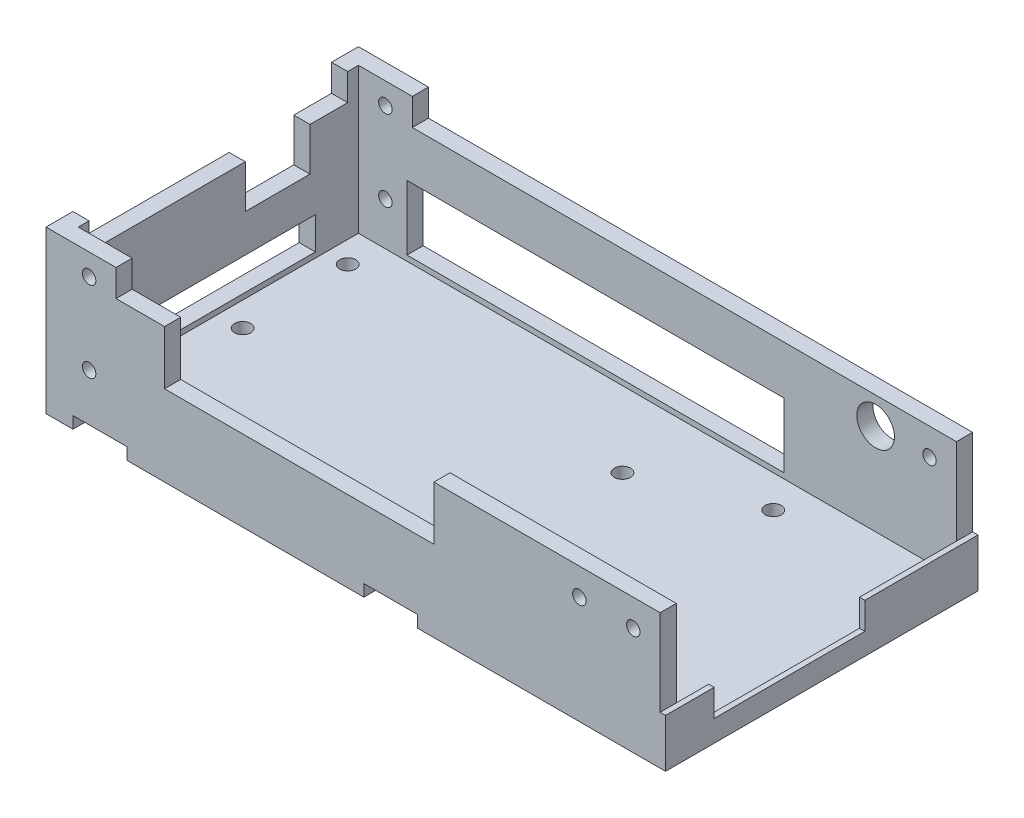
from build123d import *

# Parameters (mm, degrees)
SKETCH2_W           = 114
SKETCH2_H           = 58
BOSS_EXTRUDE1_DEPTH = 3
SKETCH3_R           = 1.5
CUT_EXTRUDE5_DEPTH  = 4
SKETCH5_R           = 3.025
CUT_EXTRUDE7_DEPTH  = 2.5
SKETCH7_W           = 3
SKETCH7_H           = 52
BOSS_EXTRUDE2_DEPTH = 22
CUT_EXTRUDE8_REACH  = 5
SKETCH8_R           = 1.5
CUT_EXTRUDE9_REACH  = 60
SKETCH9_W           = 50
SKETCH9_H           = 10
CUT_EXTRUDE10_REACH = 116
SKETCH10_W          = 32
SKETCH10_H          = 6
SKETCH10_W_2        = 12
SKETCH10_H_2        = 8
CUT_EXTRUDE11_REACH = 60
SKETCH11_W          = 70
SKETCH11_H          = 12
SKETCH12_R          = 1.25
CUT_EXTRUDE12_DEPTH = 59
SKETCH13_W          = 13
SKETCH13_H          = 5
BOSS_EXTRUDE4_DEPTH = 3
SKETCH14_W          = 13
SKETCH14_H          = 5
BOSS_EXTRUDE5_DEPTH = 3
SKETCH15_R          = 1.25
CUT_EXTRUDE13_DEPTH = 59
SKETCH16_W          = 2
SKETCH16_H          = 5
BOSS_EXTRUDE6_DEPTH = 3
CUT_EXTRUDE14_REACH = 5
SKETCH17_R          = 3.5
SKETCH19_W          = 1
SKETCH19_H          = 58
BOSS_EXTRUDE7_DEPTH = 9
CUT_EXTRUDE15_REACH = 117
SKETCH20_W          = 28
SKETCH20_H          = 5
SKETCH21_W          = 10
SKETCH21_H          = 2.5
CUT_EXTRUDE16_DEPTH = 2.2


with BuildPart() as part:
    # Sketch2 → Boss-Extrude1 (new body)
    with BuildSketch(Plane(origin=(0, 0, 0), x_dir=(1, 0, 0), z_dir=(0, 1, 0))):
        with Locations((-19.486211897, 1.601935214)):
            Rectangle(SKETCH2_W, SKETCH2_H)
    extrude(amount=BOSS_EXTRUDE1_DEPTH)

    # Sketch3 → Cut-Extrude5 (cut, through all)
    with BuildSketch(Plane(origin=(0, 3, 0), x_dir=(1, 0, 0), z_dir=(0, 1, 0))):
        with Locations((-10.486211897, 13.601935214)):
            Circle(SKETCH3_R)
        with Locations((-10.486211897, -10.398064786)):
            Circle(SKETCH3_R)
        with Locations((-68.986211897, 1.601935214)):
            Circle(SKETCH3_R)
    extrude(amount=-CUT_EXTRUDE5_DEPTH, mode=Mode.SUBTRACT)

    # Sketch5 → Cut-Extrude7 (cut)
    with BuildSketch(Plane(origin=(0, 0, 0), x_dir=(-1, 0, 0), z_dir=(0, -1, 0))):
        with Locations((23.486211897, 16.851935214)):
            Circle(SKETCH5_R)
        with Locations((23.486211897, -13.648064786)):
            Circle(SKETCH5_R)
        with Locations((53.986211897, -13.648064786)):
            Circle(SKETCH5_R)
        with Locations((53.986211897, 16.851935214)):
            Circle(SKETCH5_R)
    extrude(amount=-CUT_EXTRUDE7_DEPTH, mode=Mode.SUBTRACT)

    # Sketch7 → Boss-Extrude2 (add)
    with BuildSketch(Plane(origin=(0, 3, 0), x_dir=(1, 0, 0), z_dir=(0, 1, 0))):
        Polygon((37.513788103, 30.601935214), (-76.486211897, 30.601935214), (-76.486211897, 27.601935214), (-73.486211897, 27.601935214), (37.513788103, 27.601935214), align=None)
        with Locations((-74.986211897, 1.601935214)):
            Rectangle(SKETCH7_W, SKETCH7_H)
        Polygon((-73.486211897, -24.398064786), (-76.486211897, -24.398064786), (-76.486211897, -27.398064786), (37.513788103, -27.398064786), (37.513788103, -24.398064786), align=None)
    extrude(amount=BOSS_EXTRUDE2_DEPTH)

    # Sketch8 → Cut-Extrude8 (cut, up to next)
    with BuildSketch(Plane(origin=(0, 3, 0), x_dir=(1, 0, 0), z_dir=(0, 1, 0)), mode=Mode.PRIVATE) as cut_extrude8_sk1:
        with Locations((-69.486211897, 21.601935214)):
            Circle(SKETCH8_R)
    cut_extrude8_tool1 = extrude(cut_extrude8_sk1.sketch, amount=-CUT_EXTRUDE8_REACH, mode=Mode.PRIVATE) & part.part
    add(cut_extrude8_tool1.solids().sort_by_distance((-69.486212, 3, -21.601935))[0], mode=Mode.SUBTRACT)
    # Sketch8 → Cut-Extrude8 (cut, up to next)
    with BuildSketch(Plane(origin=(0, 3, 0), x_dir=(1, 0, 0), z_dir=(0, 1, 0)), mode=Mode.PRIVATE) as cut_extrude8_sk2:
        with Locations((-69.486211897, -20.398064786)):
            Circle(SKETCH8_R)
    cut_extrude8_tool2 = extrude(cut_extrude8_sk2.sketch, amount=-CUT_EXTRUDE8_REACH, mode=Mode.PRIVATE) & part.part
    add(cut_extrude8_tool2.solids().sort_by_distance((-69.486212, 3, 20.398065))[0], mode=Mode.SUBTRACT)
    # Sketch8 → Cut-Extrude8 (cut, up to next)
    with BuildSketch(Plane(origin=(0, 3, 0), x_dir=(1, 0, 0), z_dir=(0, 1, 0)), mode=Mode.PRIVATE) as cut_extrude8_sk3:
        with Locations((9.513788103, 21.601935214)):
            Circle(SKETCH8_R)
    cut_extrude8_tool3 = extrude(cut_extrude8_sk3.sketch, amount=-CUT_EXTRUDE8_REACH, mode=Mode.PRIVATE) & part.part
    add(cut_extrude8_tool3.solids().sort_by_distance((9.513788, 3, -21.601935))[0], mode=Mode.SUBTRACT)
    # Sketch8 → Cut-Extrude8 (cut, up to next)
    with BuildSketch(Plane(origin=(0, 3, 0), x_dir=(1, 0, 0), z_dir=(0, 1, 0)), mode=Mode.PRIVATE) as cut_extrude8_sk4:
        with Locations((9.513788103, -20.398064786)):
            Circle(SKETCH8_R)
    cut_extrude8_tool4 = extrude(cut_extrude8_sk4.sketch, amount=-CUT_EXTRUDE8_REACH, mode=Mode.PRIVATE) & part.part
    add(cut_extrude8_tool4.solids().sort_by_distance((9.513788, 3, 20.398065))[0], mode=Mode.SUBTRACT)

    # Sketch9 → Cut-Extrude9 (cut, up to next)
    with BuildSketch(Plane.XY.offset(27.398064786), mode=Mode.PRIVATE) as cut_extrude9_sk1:
        with Locations((-29.486211897, 20)):
            Rectangle(SKETCH9_W, SKETCH9_H)
    cut_extrude9_tool1 = extrude(cut_extrude9_sk1.sketch, amount=-CUT_EXTRUDE9_REACH, mode=Mode.PRIVATE) & part.part
    add(cut_extrude9_tool1.solids().sort_by_distance((-29.486212, 20, 27.398065))[0], mode=Mode.SUBTRACT)

    # Sketch10 → Cut-Extrude10 (cut, up to next)
    with BuildSketch(Plane.ZY.offset(76.486211897), mode=Mode.PRIVATE) as cut_extrude10_sk1:
        with Locations((-3.601935214, 7)):
            Rectangle(SKETCH10_W, SKETCH10_H)
    cut_extrude10_tool1 = extrude(cut_extrude10_sk1.sketch, amount=-CUT_EXTRUDE10_REACH, mode=Mode.PRIVATE) & part.part
    add(cut_extrude10_tool1.solids().sort_by_distance((-76.486212, 7, -3.601935))[0], mode=Mode.SUBTRACT)
    # Sketch10 → Cut-Extrude10 (cut, up to next)
    with BuildSketch(Plane.ZY.offset(76.486211897), mode=Mode.PRIVATE) as cut_extrude10_sk2:
        with Locations((-12.601935214, 21)):
            Rectangle(SKETCH10_W_2, SKETCH10_H_2)
    cut_extrude10_tool2 = extrude(cut_extrude10_sk2.sketch, amount=-CUT_EXTRUDE10_REACH, mode=Mode.PRIVATE) & part.part
    add(cut_extrude10_tool2.solids().sort_by_distance((-76.486212, 21, -12.601935))[0], mode=Mode.SUBTRACT)

    # Sketch11 → Cut-Extrude11 (cut, up to next)
    with BuildSketch(Plane(origin=(0, 0, -30.601935214), x_dir=(-1, 0, 0), z_dir=(0, 0, -1)), mode=Mode.PRIVATE) as cut_extrude11_sk1:
        with Locations((29.486211897, 10)):
            Rectangle(SKETCH11_W, SKETCH11_H)
    cut_extrude11_tool1 = extrude(cut_extrude11_sk1.sketch, amount=-CUT_EXTRUDE11_REACH, mode=Mode.PRIVATE) & part.part
    add(cut_extrude11_tool1.solids().sort_by_distance((-29.486212, 10, -30.601935))[0], mode=Mode.SUBTRACT)

    # Sketch12 → Cut-Extrude12 (cut, through all)
    with BuildSketch(Plane.XY.offset(27.398064786)):
        with Locations((22.513788103, 20)):
            Circle(SKETCH12_R)
        with Locations((32.513788103, 20)):
            Circle(SKETCH12_R)
        with Locations((-68.488300827, 11)):
            Circle(SKETCH12_R)
    extrude(amount=-CUT_EXTRUDE12_DEPTH, mode=Mode.SUBTRACT)

    # Sketch13 → Boss-Extrude4 (add)
    with BuildSketch(Plane.XY.offset(27.398064786)):
        with Locations((-69.986211897, 27.5)):
            Rectangle(SKETCH13_W, SKETCH13_H)
    extrude(amount=-BOSS_EXTRUDE4_DEPTH)

    # Sketch14 → Boss-Extrude5 (add)
    with BuildSketch(Plane(origin=(0, 0, -30.601935214), x_dir=(-1, 0, 0), z_dir=(0, 0, -1))):
        with Locations((69.986211897, 27.5)):
            Rectangle(SKETCH14_W, SKETCH14_H)
    extrude(amount=-BOSS_EXTRUDE5_DEPTH)

    # Sketch15 → Cut-Extrude13 (cut, through all)
    with BuildSketch(Plane.XY.offset(27.398064786)):
        with Locations((-68.486211897, 26)):
            Circle(SKETCH15_R)
    extrude(amount=-CUT_EXTRUDE13_DEPTH, mode=Mode.SUBTRACT)

    # Sketch16 → Boss-Extrude6 (add)
    with BuildSketch(Plane.ZY.offset(76.486211897)):
        with Locations((23.398064786, 27.5)):
            Rectangle(SKETCH16_W, SKETCH16_H)
        with Locations((-26.601935214, 27.5)):
            Rectangle(SKETCH16_W, SKETCH16_H)
    extrude(amount=-BOSS_EXTRUDE6_DEPTH)

    # Sketch17 → Cut-Extrude14 (cut, up to next)
    with BuildSketch(Plane.XY.offset(-27.601935214), mode=Mode.PRIVATE) as cut_extrude14_sk1:
        with Locations((22.513788103, 20)):
            Circle(SKETCH17_R)
    cut_extrude14_tool1 = extrude(cut_extrude14_sk1.sketch, amount=-CUT_EXTRUDE14_REACH, mode=Mode.PRIVATE) & part.part
    add(cut_extrude14_tool1.solids().sort_by_distance((22.513788, 20, -27.601935))[0], mode=Mode.SUBTRACT)

    # Sketch19 → Boss-Extrude7 (add)
    with BuildSketch(Plane.XZ):
        with Locations((38.013788103, -1.601935214)):
            Rectangle(SKETCH19_W, SKETCH19_H)
    extrude(amount=-BOSS_EXTRUDE7_DEPTH)

    # Sketch20 → Cut-Extrude15 (cut, up to next)
    with BuildSketch(Plane(origin=(38.513788103, 0, 0), x_dir=(0, 0, -1), z_dir=(1, 0, 0)), mode=Mode.PRIVATE) as cut_extrude15_sk1:
        with Locations((-4.398064786, 6.5)):
            Rectangle(SKETCH20_W, SKETCH20_H)
    cut_extrude15_tool1 = extrude(cut_extrude15_sk1.sketch, amount=-CUT_EXTRUDE15_REACH, mode=Mode.PRIVATE) & part.part
    add(cut_extrude15_tool1.solids().sort_by_distance((38.513788, 6.5, 4.398065))[0], mode=Mode.SUBTRACT)

    # Sketch21 → Cut-Extrude16 (cut)
    with BuildSketch(Plane(origin=(0, 0, 0), x_dir=(-1, 0, 0), z_dir=(0, -1, 0))):
        with Locations((66.486211897, -26.148064786)):
            Rectangle(SKETCH21_W, SKETCH21_H)
        with Locations((12.486211897, -26.148064786)):
            Rectangle(SKETCH21_W, SKETCH21_H)
        with Locations((12.486211897, 29.351935214)):
            Rectangle(SKETCH21_W, SKETCH21_H)
        with Locations((66.486211897, 29.351935214)):
            Rectangle(SKETCH21_W, SKETCH21_H)
    extrude(amount=-CUT_EXTRUDE16_DEPTH, mode=Mode.SUBTRACT)


solid = part.part
